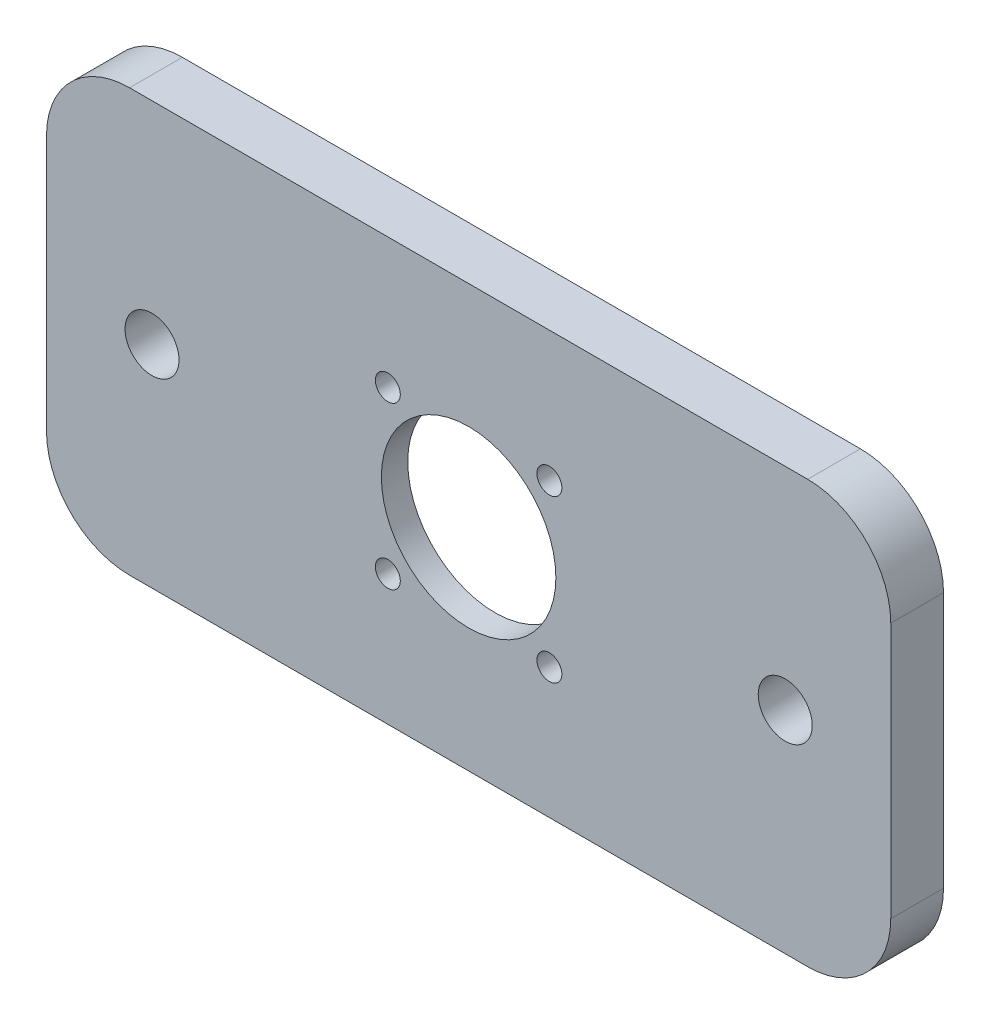
from build123d import *

# Parameters (mm, degrees)
SKETCH1_W           = 101.6
SKETCH1_H           = 50.8
SKETCH1_R           = 10.5
SKETCH1_R_2         = 1.5
BOSS_EXTRUDE1_DEPTH = 6.35
SKETCH2_R           = 21
CUT_EXTRUDE1_DEPTH  = 3.175
SKETCH3_R           = 3.25
CUT_EXTRUDE2_DEPTH  = 7.35
FILLET1_R           = 10


with BuildPart() as part:
    # Sketch1 → Boss-Extrude1 (new body)
    with BuildSketch(Plane.XY):
        with Locations((0, -0.237458689)):
            Rectangle(SKETCH1_W, SKETCH1_H)
        with Locations((0, -0.237458689)):
            Circle(SKETCH1_R, mode=Mode.SUBTRACT)
        with Locations((-9.72, 9.482541311)):
            Circle(SKETCH1_R_2, mode=Mode.SUBTRACT)
        with Locations((9.72, 9.482541311)):
            Circle(SKETCH1_R_2, mode=Mode.SUBTRACT)
        with Locations((9.72, -9.957458689)):
            Circle(SKETCH1_R_2, mode=Mode.SUBTRACT)
        with Locations((-9.72, -9.957458689)):
            Circle(SKETCH1_R_2, mode=Mode.SUBTRACT)
    extrude(amount=BOSS_EXTRUDE1_DEPTH)

    # Sketch2 → Cut-Extrude1 (cut)
    with BuildSketch(Plane(origin=(0, 0, 0), x_dir=(-1, 0, 0), z_dir=(0, 0, -1))):
        Circle(SKETCH2_R)
    extrude(amount=-CUT_EXTRUDE1_DEPTH, mode=Mode.SUBTRACT)

    # Sketch3 → Cut-Extrude2 (cut, through all)
    with BuildSketch(Plane.XY.offset(6.35)):
        with Locations((-38.1, -0.237458689)):
            Circle(SKETCH3_R)
        with Locations((38.1, -0.237458689)):
            Circle(SKETCH3_R)
    extrude(amount=-CUT_EXTRUDE2_DEPTH, mode=Mode.SUBTRACT)

    # Fillet1
    fillet1_edges = [part.edges().sort_by_distance(p)[0] for p in [
        (50.8, -25.637458689, 3.175),
        (-50.8, -25.637458689, 3.175),
        (-50.8, 25.162541311, 3.175),
        (50.8, 25.162541311, 3.175),
    ]]
    fillet(fillet1_edges, radius=FILLET1_R)


solid = part.part
